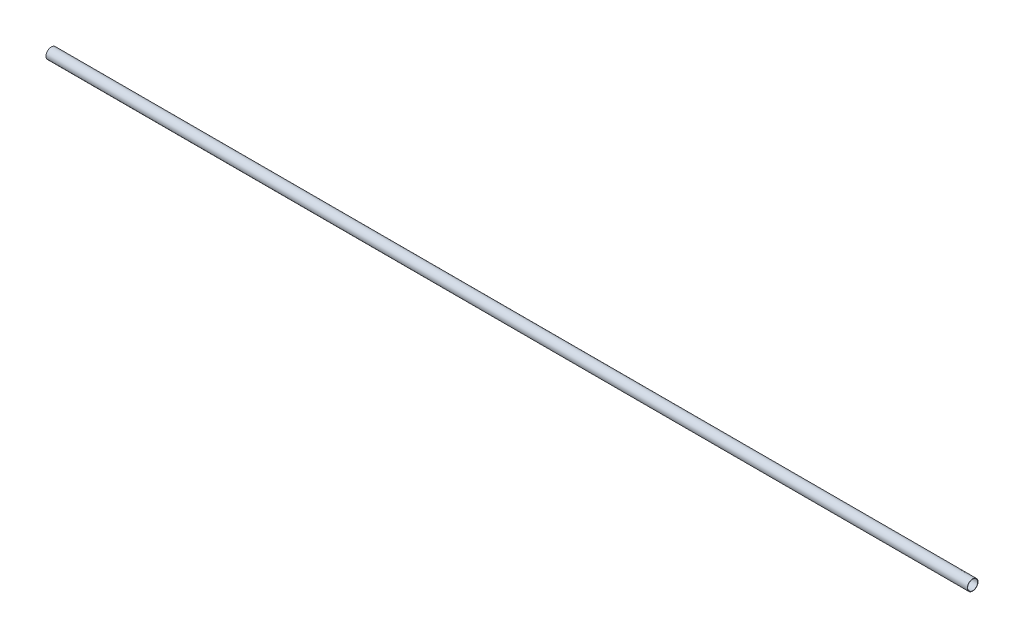
from build123d import *

# Parameters (mm, degrees)
SWEEP_THIN1_PROFILE_R   = 15
SWEEP_THIN1_PROFILE_R_2 = 14


with BuildPart() as part:
    # Sweep-Thin1: sweep along a curve in space
    with BuildLine() as sweep_thin1_path:
        Line((-31937.449283249, -17298.210932222, 40477.548756097), (-34516.470205747, -17298.210932222, 40477.548756097))
    # Sweep-Thin1 profile (on start of the path) → Sweep-Thin1 (sweep)
    with BuildSketch(Plane(origin=(-31937.449283249, -17298.210932222, 40477.548756097), x_dir=(0, 0, -1), z_dir=(-1, 0, 0))):
        Circle(SWEEP_THIN1_PROFILE_R)
        Circle(SWEEP_THIN1_PROFILE_R_2, mode=Mode.SUBTRACT)
    sweep(path=sweep_thin1_path.line)


solid = part.part
